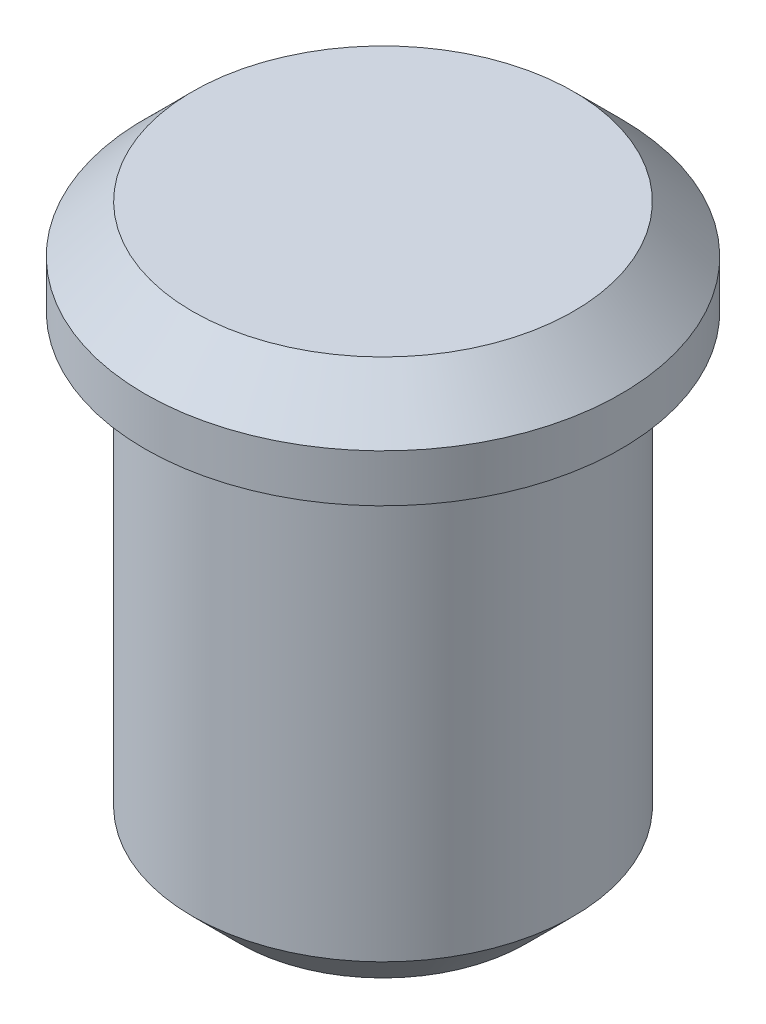
from build123d import *

# Parameters (mm, degrees)
ESBO_O1_R       = 4
EXTRUS_O1_DEPTH = 10
ESBO_O2_R       = 5
EXTRUS_O2_DEPTH = 2
CHANFRO1_SIZE   = 1
CHANFRO2_SIZE   = 1


with BuildPart() as part:
    # Esboço1 → Extrusão1 (new body)
    with BuildSketch(Plane(origin=(0, 0, 0), x_dir=(1, 0, 0), z_dir=(0, 1, 0))):
        with Locations(Location((0, 0, 0), (0, 0, 270))):  # turned: the seam where the file's is
            Circle(ESBO_O1_R)
    extrude(amount=-EXTRUS_O1_DEPTH)

    # Esboço2 → Extrusão2 (add)
    with BuildSketch(Plane(origin=(0, 0, 0), x_dir=(1, 0, 0), z_dir=(0, 1, 0))):
        with Locations(Location((0, 0, 0), (0, 0, 270))):  # turned: the seam where the file's is
            Circle(ESBO_O2_R)
    extrude(amount=EXTRUS_O2_DEPTH)

    # Chanfro1
    chanfro1_edges = [part.edges().sort_by_distance(p)[0] for p in [
        (0, -10, -4),
    ]]
    chamfer(chanfro1_edges, length=CHANFRO1_SIZE)

    # Chanfro2
    chanfro2_edges = [part.edges().sort_by_distance(p)[0] for p in [
        (0, 2, -5),
    ]]
    chamfer(chanfro2_edges, length=CHANFRO2_SIZE)


solid = part.part
